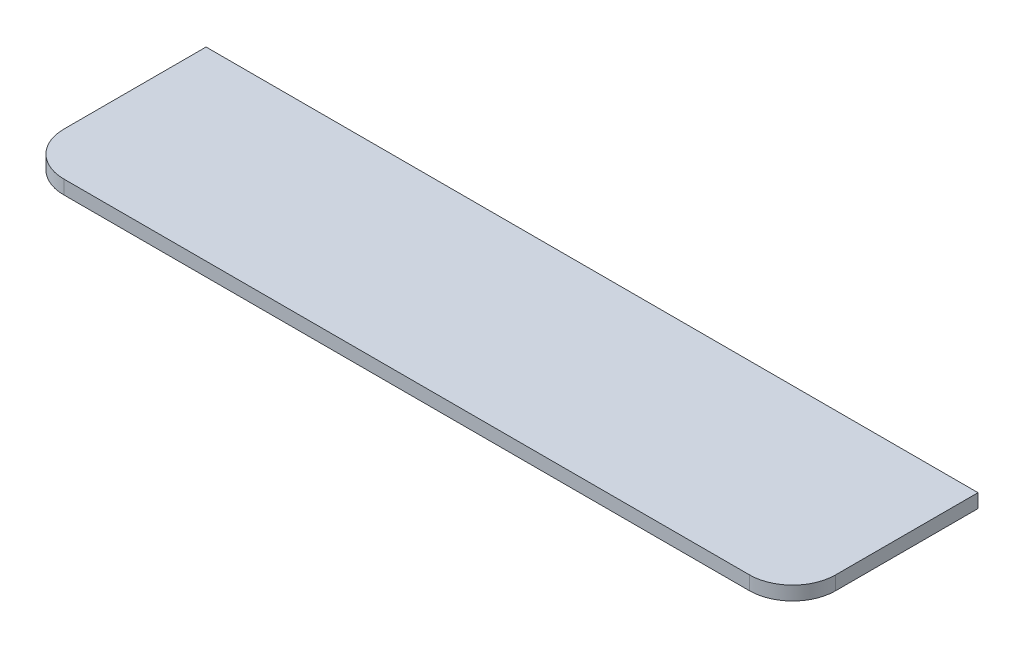
from build123d import *

# Parameters (mm, degrees)
EXTRUDE_1_DEPTH = 16


with BuildPart() as part:
    # Эскиз1 → Бобышка-Вытянуть1 (new body)
    with BuildSketch(Plane(origin=(0, 0, 0), x_dir=(1, 0, 0), z_dir=(0, 1, 0))):
        with BuildLine():
            Line((0, 0), (895, 0))
            Line((895, 0), (895, -165))
            ThreePointArc((895, -165), (880.355339059, -200.355339059), (845, -215))
            Line((845, -215), (50, -215))
            ThreePointArc((50, -215), (14.644660941, -200.355339059), (0, -165))
            Line((0, -165), (0, 0))
        make_face()
    extrude(amount=EXTRUDE_1_DEPTH)


solid = part.part
